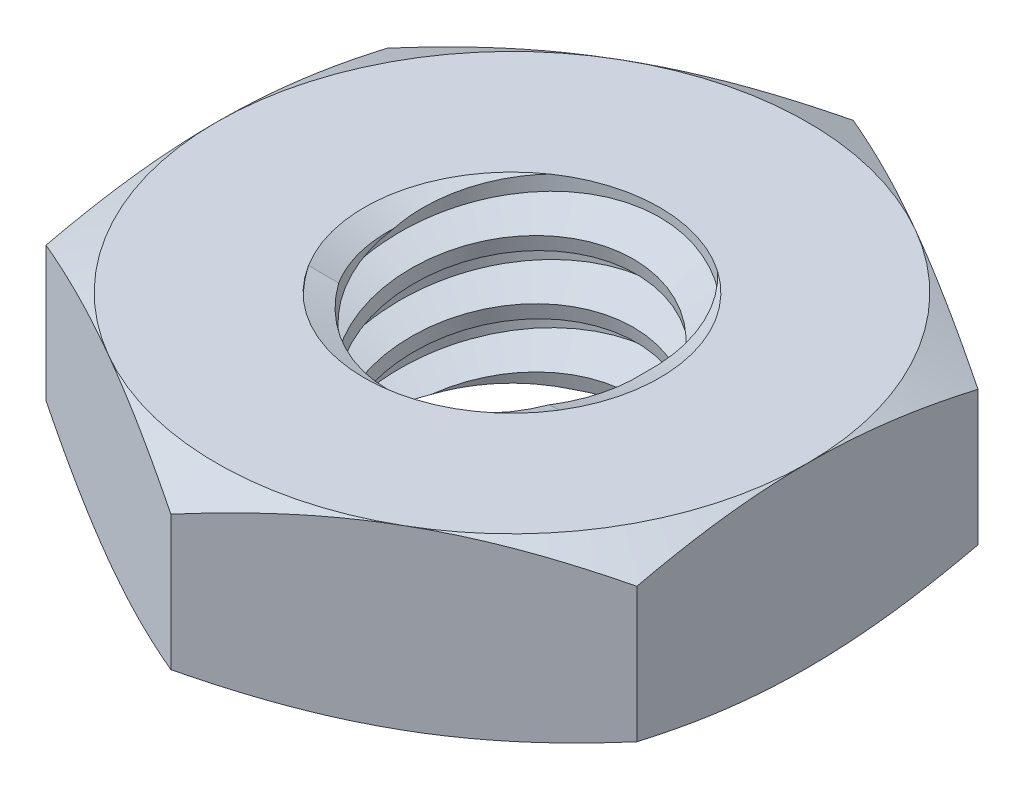
from build123d import *

# Parameters (mm, degrees)
EXTRUDE1_DEPTH      = 0.6
SKETCH2_W           = 1
SKETCH2_H           = 1.2
LPATTERN1_COUNT     = 3
LPATTERN1_PITCH     = 0.4
LPATTERN1_COL_COUNT = 2
LPATTERN1_COL_PITCH = 0.4


with BuildPart() as part:
    # Sketch1 → Extrude1 (new body, symmetric)
    with BuildSketch(Plane(origin=(0, 0, 0), x_dir=(1, 0, 0), z_dir=(0, 1, 0))):
        Polygon((0, 2.309401077), (-2, 1.154700538), (-2, -1.154700538), (0, -2.309401077), (2, -1.154700538), (2, 1.154700538), align=None)
    extrude(amount=EXTRUDE1_DEPTH, both=True)

    # Sketch4 → Cut-Revolve2 (revolve, cut)
    with BuildSketch(Plane(origin=(0, 0, 0), x_dir=(0, 0, -1), z_dir=(1, 0, 0))):
        Polygon((0, 0.6), (1, 0.6), (0.82201838, 0.517005807), (0.82201838, -0.517005807), (1, -0.6), (0, -0.6), align=None)
    revolve(axis=Axis((0, 0.6, 0), (0, 1, 0)), mode=Mode.SUBTRACT)


with BuildPart() as body_2:
    # Sketch2 → Revolve1 (revolve)
    with BuildSketch(Plane(origin=(0, 0, 0), x_dir=(0, 0, -1), z_dir=(1, 0, 0))):
        with Locations((0.5, 0)):
            Rectangle(SKETCH2_W, SKETCH2_H)
    revolve(axis=Axis((0, -1.6, 0), (0, 1, 0)))

    # Sketch3 → Cut-Revolve1 (revolve, cut)
    with BuildSketch(Plane(origin=(0, 0, 0), x_dir=(0, 0, -1), z_dir=(1, 0, 0))):
        Polygon((1.009805807, 0.550970966), (1.078446454, 0.20776773), (0.841629993, 0.287879925), (0.82201838, 0.385937993), align=None)
    cut_revolve1 = revolve(axis=Axis((0, 0.6, 0.085891176), (0, -0.980580676, -0.196116135)), mode=Mode.SUBTRACT)

    # LPattern1: Cut-Revolve1 ×3
    with Locations(*[(0, -i * LPATTERN1_PITCH, 0) for i in range(1, LPATTERN1_COUNT)]):
        add(cut_revolve1, mode=Mode.SUBTRACT)

    # LPattern1 col: Cut-Revolve1 ×2
    with Locations(*[(0, i * LPATTERN1_COL_PITCH, 0) for i in range(1, LPATTERN1_COL_COUNT)]):
        add(cut_revolve1, mode=Mode.SUBTRACT)


with BuildPart() as part_1:
    add(part.part)

    # Combine1: cut body 2
    add(body_2.part, mode=Mode.SUBTRACT)

    # Sketch5 → Cut-Revolve3 (revolve, cut)
    with BuildSketch(Plane(origin=(0, 0, 0), x_dir=(0, 0, -1), z_dir=(1, 0, 0))):
        Polygon((0, -0.6), (2, -0.6), (2.309401077, -0.455723908), (2.309401077, 0.455723908), (2, 0.6), (0, 0.6), (0, 1.87), (3.579401077, 1.87), (3.579401077, -1.87), (0, -1.87), align=None)
    revolve(axis=Axis((0, -0.6, 0), (0, 1, 0)), mode=Mode.SUBTRACT)


solid = part_1.part
